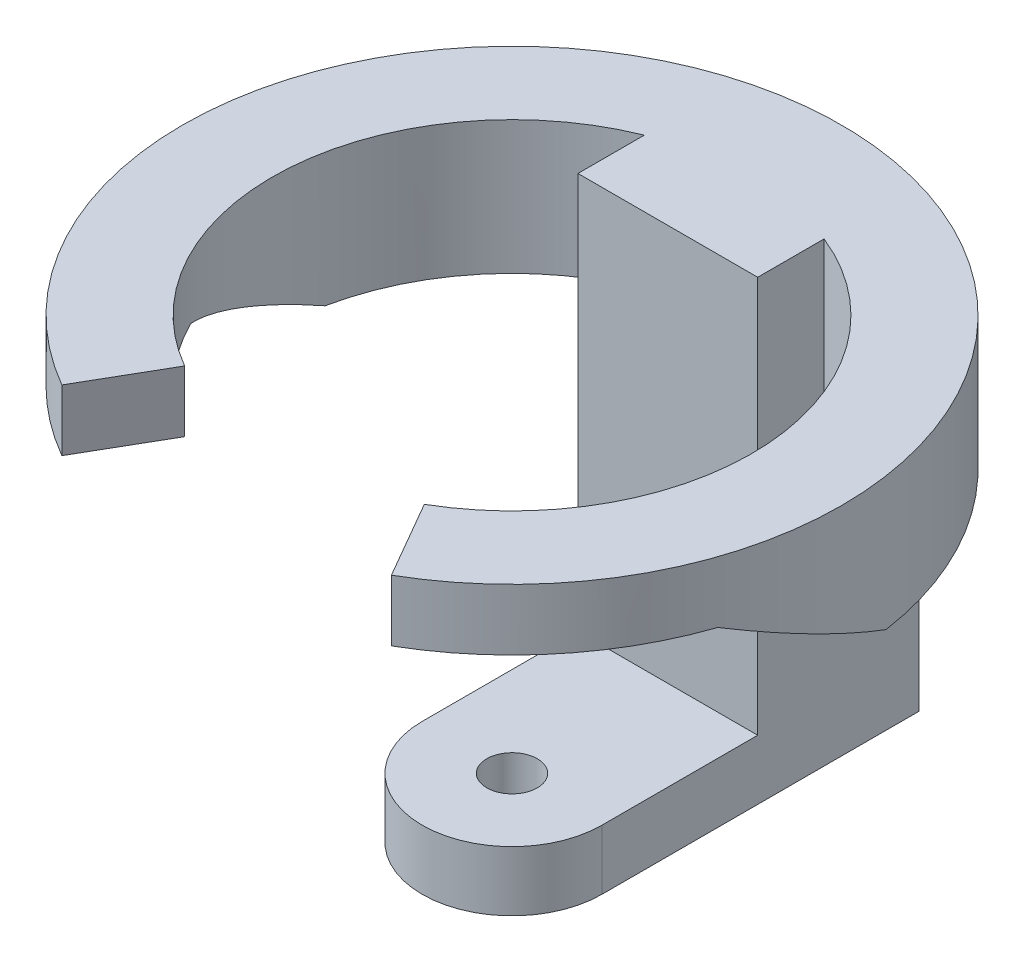
from build123d import *

# Parameters (mm, degrees)
BOSS_EXTRUDE1_DEPTH     = 10
BOSS_EXTRUDE2_START     = -10
BOSS_EXTRUDE2_DEPTH     = 76.2
SKETCH3_W               = 15
SKETCH3_H               = 22.225
REVOLVE1_ANGLE          = 300
CUT_EXTRUDE1_DEPTH      = 56
CUT_EXTRUDE1_DEPTH_BACK = 56
F_3_8_24_TAPPED_HOLE1_D = 8.4328


with BuildPart() as part:
    # Sketch1 → Boss-Extrude1 (new body)
    with BuildSketch(Plane(origin=(0, 0, 0), x_dir=(1, 0, 0), z_dir=(0, 1, 0))):
        with BuildLine():
            Line((15, 0), (15, 52.915026221))
            ThreePointArc((15, 52.915026221), (0, 55), (-15, 52.915026221))
            Line((-15, 52.915026221), (-15, 0))
            ThreePointArc((-15, 0), (0, -15), (15, 0))
        make_face()
    extrude(amount=BOSS_EXTRUDE1_DEPTH)

    # Sketch2 → Boss-Extrude2 (add)
    with BuildSketch(Plane(origin=(0, 10, 0), x_dir=(1, 0, 0), z_dir=(0, 1, 0)).offset(BOSS_EXTRUDE2_START)):
        with BuildLine():
            Line((-15, 26), (15, 26))
            Line((15, 26), (15, 52.915026221))
            ThreePointArc((15, 52.915026221), (0, 55), (-15, 52.915026221))
            Line((-15, 52.915026221), (-15, 26))
        make_face()
    extrude(amount=BOSS_EXTRUDE2_DEPTH)

    # Sketch3 → Revolve1 (revolve, symmetric)
    with BuildSketch(Plane(origin=(0, 0, 0), x_dir=(0, 0, -1), z_dir=(1, 0, 0))) as revolve1_sk:
        with Locations((47.5, 65.0875)):
            Rectangle(SKETCH3_W, SKETCH3_H)
    revolve(axis=Axis((0, 80.01, 0), (0, -1, 0)), revolution_arc=REVOLVE1_ANGLE / 2)
    revolve(revolve1_sk.sketch, axis=Axis((0, 80.01, 0), (0, 1, 0)), revolution_arc=REVOLVE1_ANGLE / 2)

    # Sketch4 → Cut-Extrude1 (cut, two sides)
    with BuildSketch(Plane(origin=(0, 0, 0), x_dir=(0, 0, -1), z_dir=(1, 0, 0))) as cut_extrude1_sk:
        Polygon((8, 53.975), (-17.734083046, 65.975), (-47.631397208, 65.975), (-47.631397208, 53.975), align=None)
    extrude(amount=CUT_EXTRUDE1_DEPTH, mode=Mode.SUBTRACT)
    extrude(cut_extrude1_sk.sketch, amount=-CUT_EXTRUDE1_DEPTH_BACK, mode=Mode.SUBTRACT)

    # 3/8-24 Tapped Hole1 (through all)
    with Locations(Plane(origin=(0, 10, 0), x_dir=(1, 0, 0), z_dir=(0, 1, 0))):
        with Locations((0, 0)):
            Hole(F_3_8_24_TAPPED_HOLE1_D / 2)


solid = part.part
